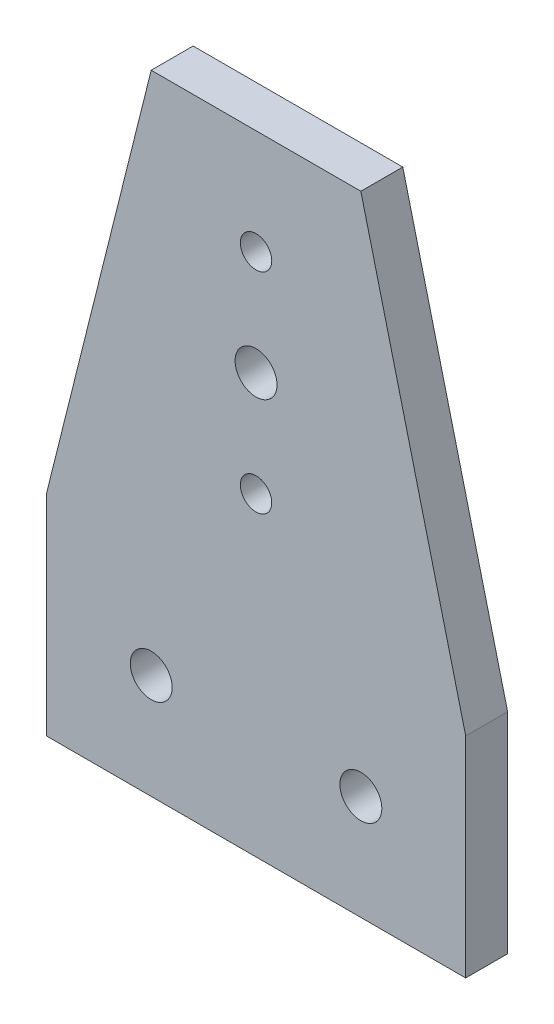
from build123d import *

# Parameters (mm, degrees)
BOSS_EXTRU_1_DEPTH      = 8
ESQUISSE2_R             = 3
ESQUISSE2_R_2           = 4
ENL_V_MAT_EXTRU_1_DEPTH = 9


with BuildPart() as part:
    # Esquisse1 → Boss.-Extru.1 (new body)
    with BuildSketch(Plane.XY):
        Polygon((-63.642103329, -47.696629213), (16.357896671, -47.696629213), (16.357896671, -7.696629213), (-3.642103329, 72.303370787), (-43.642103329, 72.303370787), (-63.642103329, -7.696629213), align=None)
    extrude(amount=BOSS_EXTRU_1_DEPTH)

    # Esquisse2 → Enlèv. mat.-Extru.1 (cut, through all)
    with BuildSketch(Plane.XY.offset(8)):
        with Locations((-23.642103329, 52.303370787)):
            Circle(ESQUISSE2_R)
        with Locations((-23.642103329, 32.303370787)):
            Circle(ESQUISSE2_R_2)
        with Locations((-23.642103329, 12.303370787)):
            Circle(ESQUISSE2_R)
        with Locations((-43.642103329, -27.696629213)):
            Circle(ESQUISSE2_R_2)
        with Locations((-3.642103329, -27.696629213)):
            Circle(ESQUISSE2_R_2)
    extrude(amount=-ENL_V_MAT_EXTRU_1_DEPTH, mode=Mode.SUBTRACT)


solid = part.part
